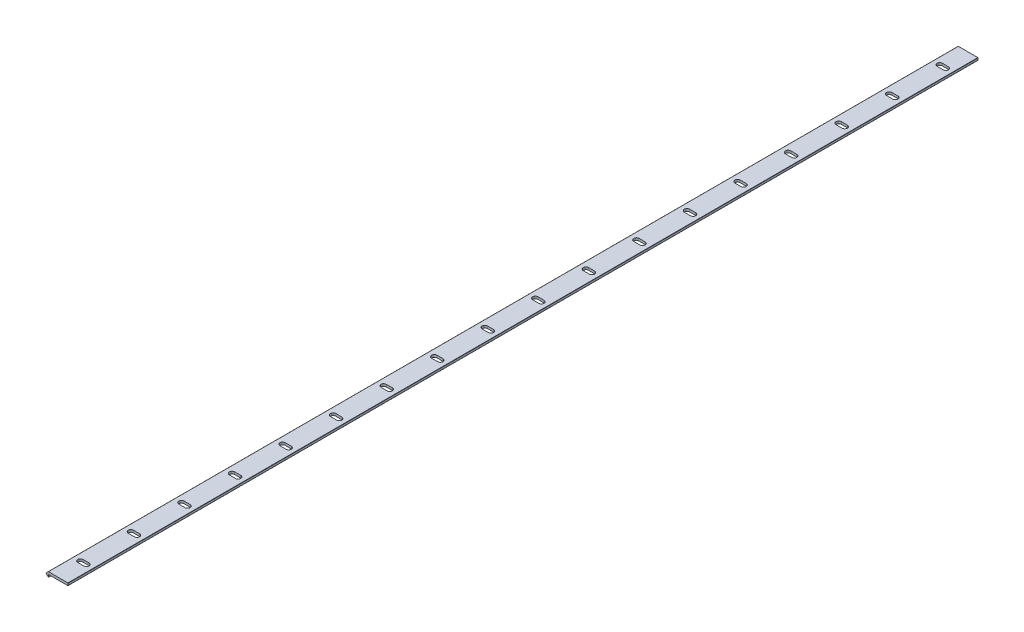
from build123d import *

# Parameters (mm, degrees)
BOSS_EXTRUDE1_DEPTH = 900
FILLET1_R           = 0.2
CUT_EXTRUDE1_DEPTH  = 2.375
LPATTERN1_COUNT     = 18
LPATTERN1_PITCH     = 50


with BuildPart() as part:
    # Sketch1 → Boss-Extrude1 (new body)
    with BuildSketch(Plane.XY):
        Polygon((0, 0), (-19.2062, 0), (-19.5291, 0), (-21.9041, -2.375), (-19.5291, -4.75), (-19.2062, -4.75), (-19.2062, -2.375), (0, -2.375), align=None)
    extrude(amount=-BOSS_EXTRUDE1_DEPTH)

    # Fillet1
    fillet1_edges = [part.edges().sort_by_distance(p)[0] for p in [
        (0, -2.375, -450),
        (-19.2062, -4.75, -450),
        (-19.5291, -4.75, -450),
        (-21.9041, -2.375, -450),
        (-19.5291, 0, -450),
        (0, 0, -450),
    ]]
    fillet(fillet1_edges, radius=FILLET1_R)

    # Sketch2 → Cut-Extrude1 (cut)
    with BuildSketch(Plane(origin=(0, 0, 0), x_dir=(1, 0, 0), z_dir=(0, 1, 0))):
        with BuildLine():
            Line((-12.823128644, 27.625), (-6.823128644, 27.625))
            ThreePointArc((-6.823128644, 27.625), (-4.198128644, 25), (-6.823128644, 22.375))
            Line((-6.823128644, 22.375), (-12.823128644, 22.375))
            ThreePointArc((-12.823128644, 22.375), (-15.448128644, 25), (-12.823128644, 27.625))
        make_face()
    cut_extrude1 = extrude(amount=-CUT_EXTRUDE1_DEPTH, mode=Mode.SUBTRACT)

    # LPattern1: Cut-Extrude1 ×18
    with Locations(*[(0, 0, -i * LPATTERN1_PITCH) for i in range(1, LPATTERN1_COUNT)]):
        add(cut_extrude1, mode=Mode.SUBTRACT)


solid = part.part
